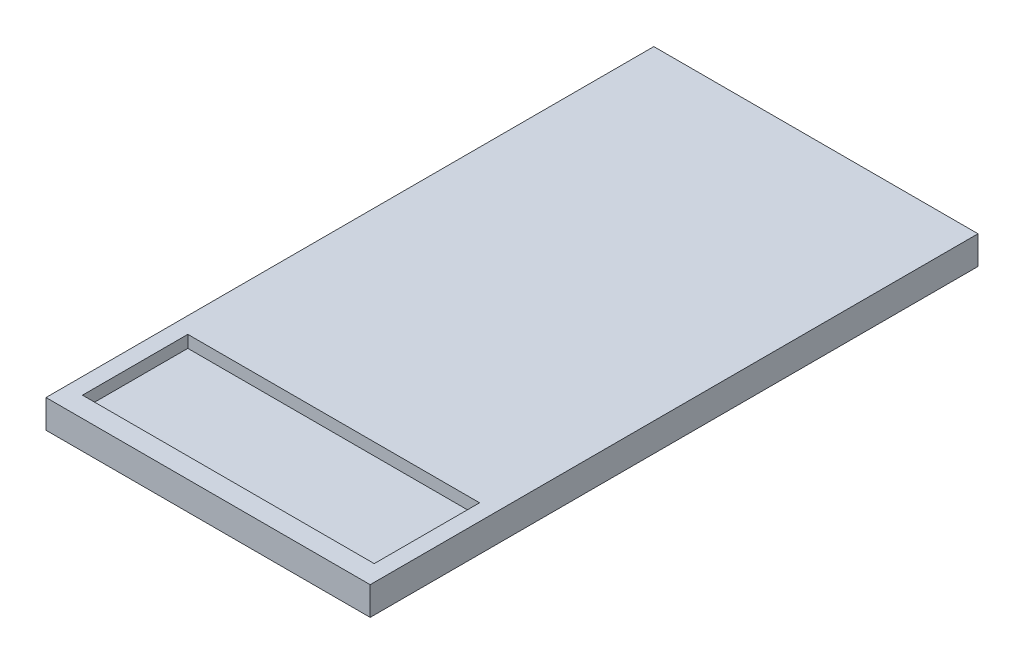
from build123d import *

# Parameters (mm, degrees)
SKETCH1_W      = 80
SKETCH1_H      = 150
EXTRUDE1_DEPTH = 7
SKETCH3_W      = 72
SKETCH3_H      = 26
EXTRUDE2_DEPTH = 3


with BuildPart() as part:
    # Sketch1 → Extrude1 (new body)
    with BuildSketch(Plane(origin=(0, 0, 0), x_dir=(1, 0, 0), z_dir=(0, 1, 0))):
        Rectangle(SKETCH1_W, SKETCH1_H)
    extrude(amount=-EXTRUDE1_DEPTH)

    # Sketch3 → Extrude2 (cut)
    with BuildSketch(Plane(origin=(0, 0, 0), x_dir=(1, 0, 0), z_dir=(0, 1, 0))):
        with Locations((0, -57)):
            Rectangle(SKETCH3_W, SKETCH3_H)
    extrude(amount=-EXTRUDE2_DEPTH, mode=Mode.SUBTRACT)


solid = part.part
